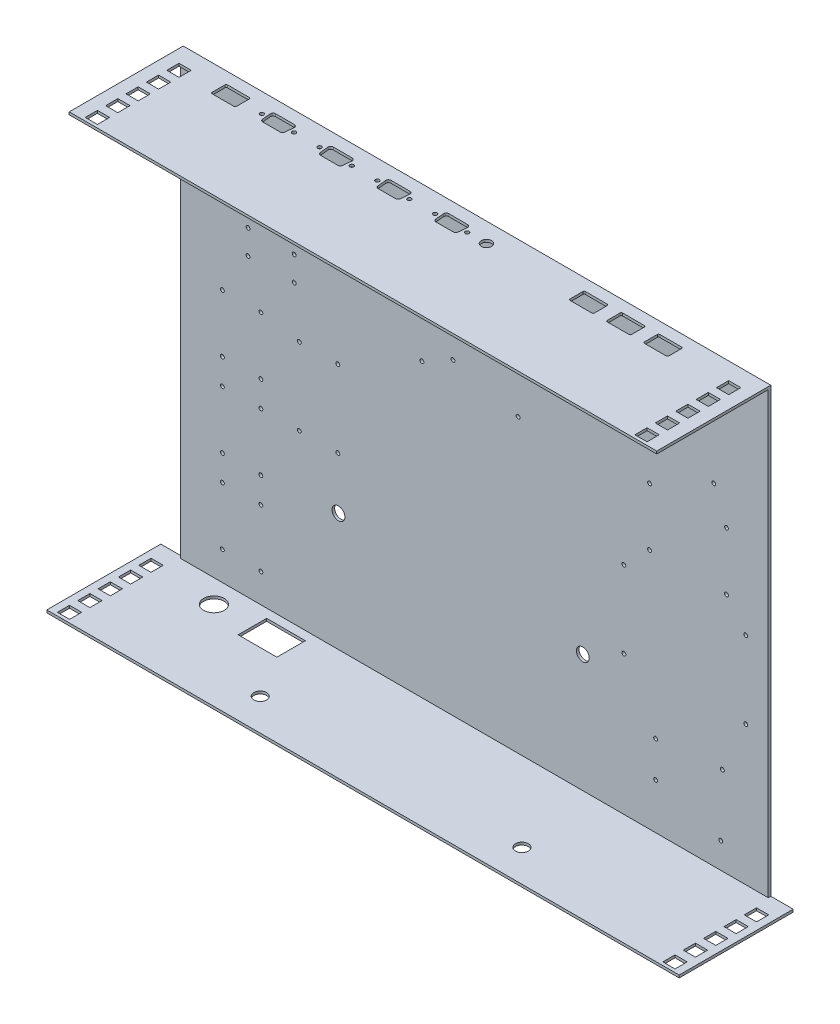
from build123d import *

# Parameters (mm, degrees)
SKETCH1_W           = 458
SKETCH1_H           = 347
BOSS_EXTRUDE1_DEPTH = 2
SKETCH4_W           = 493
SKETCH4_H           = 88.9
SKETCH4_W_2         = 9.5
SKETCH4_H_2         = 9.5
BOSS_EXTRUDE4_DEPTH = 2
CUT_EXTRUDE2_REACH  = 349
SKETCH5_W           = 17.5
SKETCH5_H           = 88.9
CUT_EXTRUDE3_REACH  = 349
SKETCH6_W           = 9.5
SKETCH6_H           = 9.5
CUT_EXTRUDE4_REACH  = 4
SKETCH9_R           = 5
CUT_EXTRUDE5_REACH  = 349
SKETCH11_R          = 5
SKETCH12_R          = 1.5
CUT_EXTRUDE6_DEPTH  = 30
SKETCH15_R          = 1.499345427
SKETCH15_R_2        = 1.5
CUT_EXTRUDE7_DEPTH  = 2
CUT_EXTRUDE9_REACH  = 349
SKETCH16_R          = 1.5
SKETCH16_R_2        = 4
CUT_EXTRUDE10_REACH = 349
SKETCH17_R          = 8.05
SKETCH17_W          = 30.2
SKETCH17_H          = 22.2


with BuildPart() as part:
    # Sketch1 → Boss-Extrude1 (new body)
    with BuildSketch(Plane.XY):
        Rectangle(SKETCH1_W, SKETCH1_H)
    extrude(amount=BOSS_EXTRUDE1_DEPTH)

    # Sketch4 → Boss-Extrude4 (add)
    with BuildSketch(Plane.XZ.offset(173.5)):
        with Locations((0, 44.45)):
            Rectangle(SKETCH4_W, SKETCH4_H)
        with Locations((-236, 65.77)):
            Rectangle(SKETCH4_W_2, SKETCH4_H_2, mode=Mode.SUBTRACT)
        with Locations((-236, 81.65)):
            Rectangle(SKETCH4_W_2, SKETCH4_H_2, mode=Mode.SUBTRACT)
        with Locations((-236, 49.89)):
            Rectangle(SKETCH4_W_2, SKETCH4_H_2, mode=Mode.SUBTRACT)
        with Locations((-236, 34.01)):
            Rectangle(SKETCH4_W_2, SKETCH4_H_2, mode=Mode.SUBTRACT)
        with Locations((-236, 18.13)):
            Rectangle(SKETCH4_W_2, SKETCH4_H_2, mode=Mode.SUBTRACT)
        with Locations((236, 18.13)):
            Rectangle(SKETCH4_W_2, SKETCH4_H_2, mode=Mode.SUBTRACT)
        with Locations((236, 34.01)):
            Rectangle(SKETCH4_W_2, SKETCH4_H_2, mode=Mode.SUBTRACT)
        with Locations((236, 49.89)):
            Rectangle(SKETCH4_W_2, SKETCH4_H_2, mode=Mode.SUBTRACT)
        with Locations((236, 65.77)):
            Rectangle(SKETCH4_W_2, SKETCH4_H_2, mode=Mode.SUBTRACT)
        with Locations((236, 81.65)):
            Rectangle(SKETCH4_W_2, SKETCH4_H_2, mode=Mode.SUBTRACT)
    boss_extrude4 = extrude(amount=-BOSS_EXTRUDE4_DEPTH)

    # Mirror1: Boss-Extrude4 across plane
    add(boss_extrude4.mirror(Plane.ZX))

    # Sketch5 → Cut-Extrude2 (cut, up to next)
    with BuildSketch(Plane(origin=(0, 173.5, 0), x_dir=(1, 0, 0), z_dir=(0, 1, 0)), mode=Mode.PRIVATE) as cut_extrude2_sk1:
        with Locations((-237.75, -44.45)):
            Rectangle(SKETCH5_W, SKETCH5_H)
    cut_extrude2_tool1 = extrude(cut_extrude2_sk1.sketch, amount=-CUT_EXTRUDE2_REACH, mode=Mode.PRIVATE) & part.part
    add(cut_extrude2_tool1.solids().sort_by_distance((-237.75, 173.5, 44.45))[0], mode=Mode.SUBTRACT)
    # Sketch5 → Cut-Extrude2 (cut, up to next)
    with BuildSketch(Plane(origin=(0, 173.5, 0), x_dir=(1, 0, 0), z_dir=(0, 1, 0)), mode=Mode.PRIVATE) as cut_extrude2_sk2:
        with Locations((237.75, -44.45)):
            Rectangle(SKETCH5_W, SKETCH5_H)
    cut_extrude2_tool2 = extrude(cut_extrude2_sk2.sketch, amount=-CUT_EXTRUDE2_REACH, mode=Mode.PRIVATE) & part.part
    add(cut_extrude2_tool2.solids().sort_by_distance((237.75, 173.5, 44.45))[0], mode=Mode.SUBTRACT)

    # Sketch6 → Cut-Extrude3 (cut, up to next)
    with BuildSketch(Plane(origin=(0, 173.5, 0), x_dir=(1, 0, 0), z_dir=(0, 1, 0)), mode=Mode.PRIVATE) as cut_extrude3_sk1:
        with Locations((-214.25, -18.07)):
            Rectangle(SKETCH6_W, SKETCH6_H)
    cut_extrude3_tool1 = extrude(cut_extrude3_sk1.sketch, amount=-CUT_EXTRUDE3_REACH, mode=Mode.PRIVATE) & part.part
    add(cut_extrude3_tool1.solids().sort_by_distance((-214.25, 173.5, 18.07))[0], mode=Mode.SUBTRACT)
    # Sketch6 → Cut-Extrude3 (cut, up to next)
    with BuildSketch(Plane(origin=(0, 173.5, 0), x_dir=(1, 0, 0), z_dir=(0, 1, 0)), mode=Mode.PRIVATE) as cut_extrude3_sk2:
        with Locations((-214.25, -33.97)):
            Rectangle(SKETCH6_W, SKETCH6_H)
    cut_extrude3_tool2 = extrude(cut_extrude3_sk2.sketch, amount=-CUT_EXTRUDE3_REACH, mode=Mode.PRIVATE) & part.part
    add(cut_extrude3_tool2.solids().sort_by_distance((-214.25, 173.5, 33.97))[0], mode=Mode.SUBTRACT)
    # Sketch6 → Cut-Extrude3 (cut, up to next)
    with BuildSketch(Plane(origin=(0, 173.5, 0), x_dir=(1, 0, 0), z_dir=(0, 1, 0)), mode=Mode.PRIVATE) as cut_extrude3_sk3:
        with Locations((-214.25, -49.87)):
            Rectangle(SKETCH6_W, SKETCH6_H)
    cut_extrude3_tool3 = extrude(cut_extrude3_sk3.sketch, amount=-CUT_EXTRUDE3_REACH, mode=Mode.PRIVATE) & part.part
    add(cut_extrude3_tool3.solids().sort_by_distance((-214.25, 173.5, 49.87))[0], mode=Mode.SUBTRACT)
    # Sketch6 → Cut-Extrude3 (cut, up to next)
    with BuildSketch(Plane(origin=(0, 173.5, 0), x_dir=(1, 0, 0), z_dir=(0, 1, 0)), mode=Mode.PRIVATE) as cut_extrude3_sk4:
        with Locations((-214.25, -65.77)):
            Rectangle(SKETCH6_W, SKETCH6_H)
    cut_extrude3_tool4 = extrude(cut_extrude3_sk4.sketch, amount=-CUT_EXTRUDE3_REACH, mode=Mode.PRIVATE) & part.part
    add(cut_extrude3_tool4.solids().sort_by_distance((-214.25, 173.5, 65.77))[0], mode=Mode.SUBTRACT)
    # Sketch6 → Cut-Extrude3 (cut, up to next)
    with BuildSketch(Plane(origin=(0, 173.5, 0), x_dir=(1, 0, 0), z_dir=(0, 1, 0)), mode=Mode.PRIVATE) as cut_extrude3_sk5:
        with Locations((-214.25, -81.67)):
            Rectangle(SKETCH6_W, SKETCH6_H)
    cut_extrude3_tool5 = extrude(cut_extrude3_sk5.sketch, amount=-CUT_EXTRUDE3_REACH, mode=Mode.PRIVATE) & part.part
    add(cut_extrude3_tool5.solids().sort_by_distance((-214.25, 173.5, 81.67))[0], mode=Mode.SUBTRACT)
    # Sketch6 → Cut-Extrude3 (cut, up to next)
    with BuildSketch(Plane(origin=(0, 173.5, 0), x_dir=(1, 0, 0), z_dir=(0, 1, 0)), mode=Mode.PRIVATE) as cut_extrude3_sk6:
        with Locations((214.25, -49.87)):
            Rectangle(SKETCH6_W, SKETCH6_H)
    cut_extrude3_tool6 = extrude(cut_extrude3_sk6.sketch, amount=-CUT_EXTRUDE3_REACH, mode=Mode.PRIVATE) & part.part
    add(cut_extrude3_tool6.solids().sort_by_distance((214.25, 173.5, 49.87))[0], mode=Mode.SUBTRACT)
    # Sketch6 → Cut-Extrude3 (cut, up to next)
    with BuildSketch(Plane(origin=(0, 173.5, 0), x_dir=(1, 0, 0), z_dir=(0, 1, 0)), mode=Mode.PRIVATE) as cut_extrude3_sk7:
        with Locations((214.25, -65.77)):
            Rectangle(SKETCH6_W, SKETCH6_H)
    cut_extrude3_tool7 = extrude(cut_extrude3_sk7.sketch, amount=-CUT_EXTRUDE3_REACH, mode=Mode.PRIVATE) & part.part
    add(cut_extrude3_tool7.solids().sort_by_distance((214.25, 173.5, 65.77))[0], mode=Mode.SUBTRACT)
    # Sketch6 → Cut-Extrude3 (cut, up to next)
    with BuildSketch(Plane(origin=(0, 173.5, 0), x_dir=(1, 0, 0), z_dir=(0, 1, 0)), mode=Mode.PRIVATE) as cut_extrude3_sk8:
        with Locations((214.25, -81.67)):
            Rectangle(SKETCH6_W, SKETCH6_H)
    cut_extrude3_tool8 = extrude(cut_extrude3_sk8.sketch, amount=-CUT_EXTRUDE3_REACH, mode=Mode.PRIVATE) & part.part
    add(cut_extrude3_tool8.solids().sort_by_distance((214.25, 173.5, 81.67))[0], mode=Mode.SUBTRACT)
    # Sketch6 → Cut-Extrude3 (cut, up to next)
    with BuildSketch(Plane(origin=(0, 173.5, 0), x_dir=(1, 0, 0), z_dir=(0, 1, 0)), mode=Mode.PRIVATE) as cut_extrude3_sk9:
        with Locations((214.25, -18.07)):
            Rectangle(SKETCH6_W, SKETCH6_H)
    cut_extrude3_tool9 = extrude(cut_extrude3_sk9.sketch, amount=-CUT_EXTRUDE3_REACH, mode=Mode.PRIVATE) & part.part
    add(cut_extrude3_tool9.solids().sort_by_distance((214.25, 173.5, 18.07))[0], mode=Mode.SUBTRACT)
    # Sketch6 → Cut-Extrude3 (cut, up to next)
    with BuildSketch(Plane(origin=(0, 173.5, 0), x_dir=(1, 0, 0), z_dir=(0, 1, 0)), mode=Mode.PRIVATE) as cut_extrude3_sk10:
        with Locations((214.25, -33.97)):
            Rectangle(SKETCH6_W, SKETCH6_H)
    cut_extrude3_tool10 = extrude(cut_extrude3_sk10.sketch, amount=-CUT_EXTRUDE3_REACH, mode=Mode.PRIVATE) & part.part
    add(cut_extrude3_tool10.solids().sort_by_distance((214.25, 173.5, 33.97))[0], mode=Mode.SUBTRACT)

    # Sketch9 → Cut-Extrude4 (cut, up to next)
    with BuildSketch(Plane.XY.offset(2), mode=Mode.PRIVATE) as cut_extrude4_sk1:
        with Locations((-106, -79.5)):
            Circle(SKETCH9_R)
    cut_extrude4_tool1 = extrude(cut_extrude4_sk1.sketch, amount=-CUT_EXTRUDE4_REACH, mode=Mode.PRIVATE) & part.part
    add(cut_extrude4_tool1.solids().sort_by_distance((-106, -79.5, 2))[0], mode=Mode.SUBTRACT)
    # Sketch9 → Cut-Extrude4 (cut, up to next)
    with BuildSketch(Plane.XY.offset(2), mode=Mode.PRIVATE) as cut_extrude4_sk2:
        with Locations((84.5, -79.5)):
            Circle(SKETCH9_R)
    cut_extrude4_tool2 = extrude(cut_extrude4_sk2.sketch, amount=-CUT_EXTRUDE4_REACH, mode=Mode.PRIVATE) & part.part
    add(cut_extrude4_tool2.solids().sort_by_distance((84.5, -79.5, 2))[0], mode=Mode.SUBTRACT)

    # Sketch11 → Cut-Extrude5 (cut, up to next)
    with BuildSketch(Plane.XZ.offset(173.5), mode=Mode.PRIVATE) as cut_extrude5_sk1:
        with Locations((-105, 64)):
            Circle(SKETCH11_R)
    cut_extrude5_tool1 = extrude(cut_extrude5_sk1.sketch, amount=-CUT_EXTRUDE5_REACH, mode=Mode.PRIVATE) & part.part
    add(cut_extrude5_tool1.solids().sort_by_distance((-105, -173.5, 64))[0], mode=Mode.SUBTRACT)
    # Sketch11 → Cut-Extrude5 (cut, up to next)
    with BuildSketch(Plane.XZ.offset(173.5), mode=Mode.PRIVATE) as cut_extrude5_sk2:
        with Locations((99, 64)):
            Circle(SKETCH11_R)
    cut_extrude5_tool2 = extrude(cut_extrude5_sk2.sketch, amount=-CUT_EXTRUDE5_REACH, mode=Mode.PRIVATE) & part.part
    add(cut_extrude5_tool2.solids().sort_by_distance((99, -173.5, 64))[0], mode=Mode.SUBTRACT)

    # Sketch12 → Cut-Extrude6 (cut)
    with BuildSketch(Plane.XY.offset(2)):
        with Locations((-196.5, -149)):
            Circle(SKETCH12_R)
        with Locations((-166.5, -149)):
            Circle(SKETCH12_R)
        with Locations((-196.5, -84)):
            Circle(SKETCH12_R)
        with Locations((-166.5, -84)):
            Circle(SKETCH12_R)
        with Locations((-196.5, -39)):
            Circle(SKETCH12_R)
        with Locations((-166.5, -39)):
            Circle(SKETCH12_R)
        with Locations((-196.5, -19)):
            Circle(SKETCH12_R)
        with Locations((-196.5, -104)):
            Circle(SKETCH12_R)
        with Locations((-166.5, -104)):
            Circle(SKETCH12_R)
        with Locations((-166.5, -19)):
            Circle(SKETCH12_R)
        with Locations((-136.5, -39)):
            Circle(SKETCH12_R)
        with Locations((-106.5, -39)):
            Circle(SKETCH12_R)
        with Locations((-136.5, 21)):
            Circle(SKETCH12_R)
        with Locations((-106.5, 21)):
            Circle(SKETCH12_R)
        with Locations((-166.5, 26)):
            Circle(SKETCH12_R)
        with Locations((-196.5, 26)):
            Circle(SKETCH12_R)
    extrude(amount=-CUT_EXTRUDE6_DEPTH, mode=Mode.SUBTRACT)

    # Sketch15 → Cut-Extrude7 (cut)
    with BuildSketch(Plane.XY.offset(2)):
        with Locations((-176.5, 78)):
            Circle(SKETCH15_R)
        with Locations((-176.5, 59)):
            Circle(SKETCH15_R_2)
        with Locations((-140.5, 59)):
            Circle(SKETCH15_R_2)
        with Locations((-140.5, 78)):
            Circle(SKETCH15_R_2)
        with Locations((116.5, -3)):
            Circle(SKETCH15_R_2)
        with Locations((116.5, -63)):
            Circle(SKETCH15_R_2)
        with Locations((211.5, -63)):
            Circle(SKETCH15_R_2)
        with Locations((211.5, -3)):
            Circle(SKETCH15_R_2)
        with Locations((136.5, 62)):
            Circle(SKETCH15_R_2)
        with Locations((136.5, 17)):
            Circle(SKETCH15_R_2)
        with Locations((196.5, 17)):
            Circle(SKETCH15_R_2)
        with Locations((196.5, 62)):
            Circle(SKETCH15_R_2)
        with Locations((96.5, 134)):
            Circle(SKETCH15_R_2)
        with Locations((96.5, 87)):
            Circle(SKETCH15_R_2)
        with Locations((186.5, 87)):
            Circle(SKETCH15_R_2)
        with Locations((186.5, 134)):
            Circle(SKETCH15_R_2)
        with Locations((35.28, 104.261)):
            Circle(SKETCH15_R_2)
        with Locations((-47.198, 104.261)):
            Circle(SKETCH15_R_2)
        with Locations((-40.945, 55.739)):
            Circle(SKETCH15_R_2)
        with Locations((34.01, 55.739)):
            Circle(SKETCH15_R_2)
        with Locations((-16.75, 96.644)):
            Circle(SKETCH15_R_2)
        with Locations((-16.75, 68.735)):
            Circle(SKETCH15_R_2)
        with Locations((193.28, -102.889)):
            Circle(SKETCH15_R_2)
        with Locations((192.015, -151.411)):
            Circle(SKETCH15_R_2)
        with Locations((141.25, -107.967)):
            Circle(SKETCH15_R_2)
        with Locations((141.25, -135.876)):
            Circle(SKETCH15_R_2)
    extrude(amount=-CUT_EXTRUDE7_DEPTH, mode=Mode.SUBTRACT)

    # Sketch16 → Cut-Extrude9 (cut, up to next)
    with BuildSketch(Plane(origin=(0, 173.5, 0), x_dir=(1, 0, 0), z_dir=(0, 1, 0)), mode=Mode.PRIVATE) as cut_extrude9_sk1:
        with Locations((-152.502278756, -15.187845189)):
            Circle(SKETCH16_R)
    cut_extrude9_tool1 = extrude(cut_extrude9_sk1.sketch, amount=-CUT_EXTRUDE9_REACH, mode=Mode.PRIVATE) & part.part
    add(cut_extrude9_tool1.solids().sort_by_distance((-152.502279, 173.5, 15.187845))[0], mode=Mode.SUBTRACT)
    # Sketch16 → Cut-Extrude9 (cut, up to next)
    with BuildSketch(Plane(origin=(0, 173.5, 0), x_dir=(1, 0, 0), z_dir=(0, 1, 0)), mode=Mode.PRIVATE) as cut_extrude9_sk2:
        with Locations((-127.497721244, -15.187845189)):
            Circle(SKETCH16_R)
    cut_extrude9_tool2 = extrude(cut_extrude9_sk2.sketch, amount=-CUT_EXTRUDE9_REACH, mode=Mode.PRIVATE) & part.part
    add(cut_extrude9_tool2.solids().sort_by_distance((-127.497721, 173.5, 15.187845))[0], mode=Mode.SUBTRACT)
    # Sketch16 → Cut-Extrude9 (cut, up to next)
    with BuildSketch(Plane(origin=(0, 173.5, 0), x_dir=(1, 0, 0), z_dir=(0, 1, 0)), mode=Mode.PRIVATE) as cut_extrude9_sk3:
        with Locations((-107.502278756, -15.187845189)):
            Circle(SKETCH16_R)
    cut_extrude9_tool3 = extrude(cut_extrude9_sk3.sketch, amount=-CUT_EXTRUDE9_REACH, mode=Mode.PRIVATE) & part.part
    add(cut_extrude9_tool3.solids().sort_by_distance((-107.502279, 173.5, 15.187845))[0], mode=Mode.SUBTRACT)
    # Sketch16 → Cut-Extrude9 (cut, up to next)
    with BuildSketch(Plane(origin=(0, 173.5, 0), x_dir=(1, 0, 0), z_dir=(0, 1, 0)), mode=Mode.PRIVATE) as cut_extrude9_sk4:
        with Locations((-82.497721244, -15.187845189)):
            Circle(SKETCH16_R)
    cut_extrude9_tool4 = extrude(cut_extrude9_sk4.sketch, amount=-CUT_EXTRUDE9_REACH, mode=Mode.PRIVATE) & part.part
    add(cut_extrude9_tool4.solids().sort_by_distance((-82.497721, 173.5, 15.187845))[0], mode=Mode.SUBTRACT)
    # Sketch16 → Cut-Extrude9 (cut, up to next)
    with BuildSketch(Plane(origin=(0, 173.5, 0), x_dir=(1, 0, 0), z_dir=(0, 1, 0)), mode=Mode.PRIVATE) as cut_extrude9_sk5:
        with Locations((-62.502278756, -15.187845189)):
            Circle(SKETCH16_R)
    cut_extrude9_tool5 = extrude(cut_extrude9_sk5.sketch, amount=-CUT_EXTRUDE9_REACH, mode=Mode.PRIVATE) & part.part
    add(cut_extrude9_tool5.solids().sort_by_distance((-62.502279, 173.5, 15.187845))[0], mode=Mode.SUBTRACT)
    # Sketch16 → Cut-Extrude9 (cut, up to next)
    with BuildSketch(Plane(origin=(0, 173.5, 0), x_dir=(1, 0, 0), z_dir=(0, 1, 0)), mode=Mode.PRIVATE) as cut_extrude9_sk6:
        with Locations((-37.497721244, -15.187845189)):
            Circle(SKETCH16_R)
    cut_extrude9_tool6 = extrude(cut_extrude9_sk6.sketch, amount=-CUT_EXTRUDE9_REACH, mode=Mode.PRIVATE) & part.part
    add(cut_extrude9_tool6.solids().sort_by_distance((-37.497721, 173.5, 15.187845))[0], mode=Mode.SUBTRACT)
    # Sketch16 → Cut-Extrude9 (cut, up to next)
    with BuildSketch(Plane(origin=(0, 173.5, 0), x_dir=(1, 0, 0), z_dir=(0, 1, 0)), mode=Mode.PRIVATE) as cut_extrude9_sk7:
        with Locations((-17.502278756, -15.187845189)):
            Circle(SKETCH16_R)
    cut_extrude9_tool7 = extrude(cut_extrude9_sk7.sketch, amount=-CUT_EXTRUDE9_REACH, mode=Mode.PRIVATE) & part.part
    add(cut_extrude9_tool7.solids().sort_by_distance((-17.502279, 173.5, 15.187845))[0], mode=Mode.SUBTRACT)
    # Sketch16 → Cut-Extrude9 (cut, up to next)
    with BuildSketch(Plane(origin=(0, 173.5, 0), x_dir=(1, 0, 0), z_dir=(0, 1, 0)), mode=Mode.PRIVATE) as cut_extrude9_sk8:
        with Locations((7.502278756, -15.187845189)):
            Circle(SKETCH16_R)
    cut_extrude9_tool8 = extrude(cut_extrude9_sk8.sketch, amount=-CUT_EXTRUDE9_REACH, mode=Mode.PRIVATE) & part.part
    add(cut_extrude9_tool8.solids().sort_by_distance((7.502279, 173.5, 15.187845))[0], mode=Mode.SUBTRACT)
    # Sketch16 → Cut-Extrude9 (cut, up to next)
    with BuildSketch(Plane(origin=(0, 173.5, 0), x_dir=(1, 0, 0), z_dir=(0, 1, 0)), mode=Mode.PRIVATE) as cut_extrude9_sk9:
        with Locations((22.502278756, -15.187845189)):
            Circle(SKETCH16_R_2)
    cut_extrude9_tool9 = extrude(cut_extrude9_sk9.sketch, amount=-CUT_EXTRUDE9_REACH, mode=Mode.PRIVATE) & part.part
    add(cut_extrude9_tool9.solids().sort_by_distance((22.502279, 173.5, 15.187845))[0], mode=Mode.SUBTRACT)
    # Sketch16 → Cut-Extrude9 (cut, up to next)
    with BuildSketch(Plane(origin=(0, 173.5, 0), x_dir=(1, 0, 0), z_dir=(0, 1, 0)), mode=Mode.PRIVATE) as cut_extrude9_sk10:
        with BuildLine():
            Line((-147.352440505, -9.7), (-132.647559495, -9.7))
            ThreePointArc((-132.647559495, -9.7), (-131.168422859, -10.353837004), (-130.65640049, -11.887845189))
            Line((-130.65640049, -11.887845189), (-131.279041999, -18.487845189))
            ThreePointArc((-131.279041999, -18.487845189), (-131.924038009, -19.779136636), (-133.270201004, -20.3))
            Line((-133.270201004, -20.3), (-146.729798996, -20.3))
            ThreePointArc((-146.729798996, -20.3), (-148.075961991, -19.779136636), (-148.720958001, -18.487845189))
            Line((-148.720958001, -18.487845189), (-149.34359951, -11.887845189))
            ThreePointArc((-149.34359951, -11.887845189), (-148.831577141, -10.353837004), (-147.352440505, -9.7))
        make_face()
    cut_extrude9_tool10 = extrude(cut_extrude9_sk10.sketch, amount=-CUT_EXTRUDE9_REACH, mode=Mode.PRIVATE) & part.part
    add(cut_extrude9_tool10.solids().sort_by_distance((-140, 173.5, 14.919182))[0], mode=Mode.SUBTRACT)
    # Sketch16 → Cut-Extrude9 (cut, up to next)
    with BuildSketch(Plane(origin=(0, 173.5, 0), x_dir=(1, 0, 0), z_dir=(0, 1, 0)), mode=Mode.PRIVATE) as cut_extrude9_sk11:
        with BuildLine():
            Line((-102.352440505, -9.7), (-87.647559495, -9.7))
            ThreePointArc((-87.647559495, -9.7), (-86.168422859, -10.353837004), (-85.65640049, -11.887845189))
            Line((-85.65640049, -11.887845189), (-86.279041999, -18.487845189))
            ThreePointArc((-86.279041999, -18.487845189), (-86.924038009, -19.779136636), (-88.270201004, -20.3))
            Line((-88.270201004, -20.3), (-101.729798996, -20.3))
            ThreePointArc((-101.729798996, -20.3), (-103.075961991, -19.779136636), (-103.720958001, -18.487845189))
            Line((-103.720958001, -18.487845189), (-104.34359951, -11.887845189))
            ThreePointArc((-104.34359951, -11.887845189), (-103.831577141, -10.353837004), (-102.352440505, -9.7))
        make_face()
    cut_extrude9_tool11 = extrude(cut_extrude9_sk11.sketch, amount=-CUT_EXTRUDE9_REACH, mode=Mode.PRIVATE) & part.part
    add(cut_extrude9_tool11.solids().sort_by_distance((-95, 173.5, 14.919182))[0], mode=Mode.SUBTRACT)
    # Sketch16 → Cut-Extrude9 (cut, up to next)
    with BuildSketch(Plane(origin=(0, 173.5, 0), x_dir=(1, 0, 0), z_dir=(0, 1, 0)), mode=Mode.PRIVATE) as cut_extrude9_sk12:
        with BuildLine():
            Line((-57.352440505, -9.7), (-42.647559495, -9.7))
            ThreePointArc((-42.647559495, -9.7), (-41.168422859, -10.353837004), (-40.65640049, -11.887845189))
            Line((-40.65640049, -11.887845189), (-41.279041999, -18.487845189))
            ThreePointArc((-41.279041999, -18.487845189), (-41.924038009, -19.779136636), (-43.270201004, -20.3))
            Line((-43.270201004, -20.3), (-56.729798996, -20.3))
            ThreePointArc((-56.729798996, -20.3), (-58.075961991, -19.779136636), (-58.720958001, -18.487845189))
            Line((-58.720958001, -18.487845189), (-59.34359951, -11.887845189))
            ThreePointArc((-59.34359951, -11.887845189), (-58.831577141, -10.353837004), (-57.352440505, -9.7))
        make_face()
    cut_extrude9_tool12 = extrude(cut_extrude9_sk12.sketch, amount=-CUT_EXTRUDE9_REACH, mode=Mode.PRIVATE) & part.part
    add(cut_extrude9_tool12.solids().sort_by_distance((-50, 173.5, 14.919182))[0], mode=Mode.SUBTRACT)
    # Sketch16 → Cut-Extrude9 (cut, up to next)
    with BuildSketch(Plane(origin=(0, 173.5, 0), x_dir=(1, 0, 0), z_dir=(0, 1, 0)), mode=Mode.PRIVATE) as cut_extrude9_sk13:
        with BuildLine():
            Line((-12.352440505, -9.7), (2.352440505, -9.7))
            ThreePointArc((2.352440505, -9.7), (3.831577141, -10.353837004), (4.34359951, -11.887845189))
            Line((4.34359951, -11.887845189), (3.720958001, -18.487845189))
            ThreePointArc((3.720958001, -18.487845189), (3.075961991, -19.779136636), (1.729798996, -20.3))
            Line((1.729798996, -20.3), (-11.729798996, -20.3))
            ThreePointArc((-11.729798996, -20.3), (-13.075961991, -19.779136636), (-13.720958001, -18.487845189))
            Line((-13.720958001, -18.487845189), (-14.34359951, -11.887845189))
            ThreePointArc((-14.34359951, -11.887845189), (-13.831577141, -10.353837004), (-12.352440505, -9.7))
        make_face()
    cut_extrude9_tool13 = extrude(cut_extrude9_sk13.sketch, amount=-CUT_EXTRUDE9_REACH, mode=Mode.PRIVATE) & part.part
    add(cut_extrude9_tool13.solids().sort_by_distance((-5, 173.5, 14.919182))[0], mode=Mode.SUBTRACT)
    # Sketch16 → Cut-Extrude9 (cut, up to next)
    with BuildSketch(Plane(origin=(0, 173.5, 0), x_dir=(1, 0, 0), z_dir=(0, 1, 0)), mode=Mode.PRIVATE) as cut_extrude9_sk14:
        with BuildLine():
            Line((-185.502278756, -21), (-168.502278756, -21))
            ThreePointArc((-168.502278756, -21), (-167.795171975, -20.707106781), (-167.502278756, -20))
            Line((-167.502278756, -20), (-167.502278756, -10))
            ThreePointArc((-167.502278756, -10), (-167.795171975, -9.292893219), (-168.502278756, -9))
            Line((-168.502278756, -9), (-185.502278756, -9))
            ThreePointArc((-185.502278756, -9), (-186.209385537, -9.292893219), (-186.502278756, -10))
            Line((-186.502278756, -10), (-186.502278756, -20))
            ThreePointArc((-186.502278756, -20), (-186.209385537, -20.707106781), (-185.502278756, -21))
        make_face()
    cut_extrude9_tool14 = extrude(cut_extrude9_sk14.sketch, amount=-CUT_EXTRUDE9_REACH, mode=Mode.PRIVATE) & part.part
    add(cut_extrude9_tool14.solids().sort_by_distance((-177.002279, 173.5, 15))[0], mode=Mode.SUBTRACT)
    # Sketch16 → Cut-Extrude9 (cut, up to next)
    with BuildSketch(Plane(origin=(0, 173.5, 0), x_dir=(1, 0, 0), z_dir=(0, 1, 0)), mode=Mode.PRIVATE) as cut_extrude9_sk15:
        with BuildLine():
            Line((122.502278756, -21), (139.502278756, -21))
            ThreePointArc((139.502278756, -21), (140.209385537, -20.707106781), (140.502278756, -20))
            Line((140.502278756, -20), (140.502278756, -10))
            ThreePointArc((140.502278756, -10), (140.209385537, -9.292893219), (139.502278756, -9))
            Line((139.502278756, -9), (122.502278756, -9))
            ThreePointArc((122.502278756, -9), (121.795171975, -9.292893219), (121.502278756, -10))
            Line((121.502278756, -10), (121.502278756, -20))
            ThreePointArc((121.502278756, -20), (121.795171975, -20.707106781), (122.502278756, -21))
        make_face()
    cut_extrude9_tool15 = extrude(cut_extrude9_sk15.sketch, amount=-CUT_EXTRUDE9_REACH, mode=Mode.PRIVATE) & part.part
    add(cut_extrude9_tool15.solids().sort_by_distance((131.002279, 173.5, 15))[0], mode=Mode.SUBTRACT)
    # Sketch16 → Cut-Extrude9 (cut, up to next)
    with BuildSketch(Plane(origin=(0, 173.5, 0), x_dir=(1, 0, 0), z_dir=(0, 1, 0)), mode=Mode.PRIVATE) as cut_extrude9_sk16:
        with BuildLine():
            Line((151.502278756, -21), (168.502278756, -21))
            ThreePointArc((168.502278756, -21), (169.209385537, -20.707106781), (169.502278756, -20))
            Line((169.502278756, -20), (169.502278756, -10))
            ThreePointArc((169.502278756, -10), (169.209385537, -9.292893219), (168.502278756, -9))
            Line((168.502278756, -9), (151.502278756, -9))
            ThreePointArc((151.502278756, -9), (150.795171975, -9.292893219), (150.502278756, -10))
            Line((150.502278756, -10), (150.502278756, -20))
            ThreePointArc((150.502278756, -20), (150.795171975, -20.707106781), (151.502278756, -21))
        make_face()
    cut_extrude9_tool16 = extrude(cut_extrude9_sk16.sketch, amount=-CUT_EXTRUDE9_REACH, mode=Mode.PRIVATE) & part.part
    add(cut_extrude9_tool16.solids().sort_by_distance((160.002279, 173.5, 15))[0], mode=Mode.SUBTRACT)
    # Sketch16 → Cut-Extrude9 (cut, up to next)
    with BuildSketch(Plane(origin=(0, 173.5, 0), x_dir=(1, 0, 0), z_dir=(0, 1, 0)), mode=Mode.PRIVATE) as cut_extrude9_sk17:
        with BuildLine():
            Line((93.502278756, -21), (110.502278756, -21))
            ThreePointArc((110.502278756, -21), (111.209385537, -20.707106781), (111.502278756, -20))
            Line((111.502278756, -20), (111.502278756, -10))
            ThreePointArc((111.502278756, -10), (111.209385537, -9.292893219), (110.502278756, -9))
            Line((110.502278756, -9), (93.502278756, -9))
            ThreePointArc((93.502278756, -9), (92.795171975, -9.292893219), (92.502278756, -10))
            Line((92.502278756, -10), (92.502278756, -20))
            ThreePointArc((92.502278756, -20), (92.795171975, -20.707106781), (93.502278756, -21))
        make_face()
    cut_extrude9_tool17 = extrude(cut_extrude9_sk17.sketch, amount=-CUT_EXTRUDE9_REACH, mode=Mode.PRIVATE) & part.part
    add(cut_extrude9_tool17.solids().sort_by_distance((102.002279, 173.5, 15))[0], mode=Mode.SUBTRACT)

    # Sketch17 → Cut-Extrude10 (cut, up to next)
    with BuildSketch(Plane.XZ.offset(173.5), mode=Mode.PRIVATE) as cut_extrude10_sk1:
        with Locations((-185.1, 20)):
            Circle(SKETCH17_R)
    cut_extrude10_tool1 = extrude(cut_extrude10_sk1.sketch, amount=-CUT_EXTRUDE10_REACH, mode=Mode.PRIVATE) & part.part
    add(cut_extrude10_tool1.solids().sort_by_distance((-185.1, -173.5, 20))[0], mode=Mode.SUBTRACT)
    # Sketch17 → Cut-Extrude10 (cut, up to next)
    with BuildSketch(Plane.XZ.offset(173.5), mode=Mode.PRIVATE) as cut_extrude10_sk2:
        with Locations((-140, 20)):
            Rectangle(SKETCH17_W, SKETCH17_H)
    cut_extrude10_tool2 = extrude(cut_extrude10_sk2.sketch, amount=-CUT_EXTRUDE10_REACH, mode=Mode.PRIVATE) & part.part
    add(cut_extrude10_tool2.solids().sort_by_distance((-140, -173.5, 20))[0], mode=Mode.SUBTRACT)


solid = part.part
